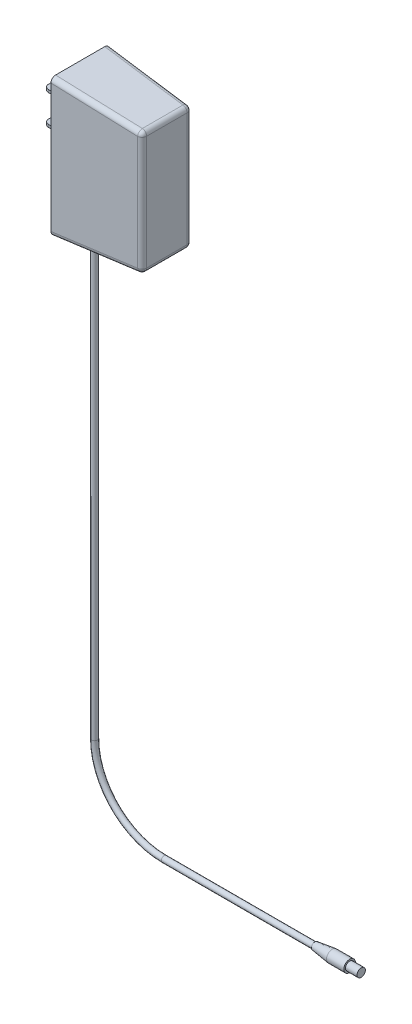
from build123d import *

# Parameters (mm, degrees)
SKETCH2_R           = 1.5875
SKETCH3_R           = 3.175
BOSS_EXTRUDE1_DEPTH = 19.05
SKETCH4_R           = 2.286
BOSS_EXTRUDE2_DEPTH = 6.35
CHAMFER1_SIZE       = 1.27
CHAMFER1_SIZE2      = 9.525
SKETCH5_W           = 47.5
SKETCH5_H           = 75.5
BOSS_EXTRUDE3_DEPTH = 16
SKETCH6_W           = 8
SKETCH6_H           = 1.5
BOSS_EXTRUDE4_DEPTH = 15.88
DRAFT1_ANGLE        = -5
DRAFT2_ANGLE        = -3
FILLET1_R           = 2.54
FILLET2_R           = 2.54


with BuildPart() as part:
    # Sweep1: sweep along a path in Sketch1
    with BuildLine(Plane.XY) as sweep1_path:
        Line((0, 0), (-101.6, 0))
        ThreePointArc((-101.6, 0), (-128.540768363, 11.159231637), (-139.7, 38.1))
        Line((-139.7, 38.1), (-139.7, 355.6))
    # Sketch2 → Sweep1 (sweep)
    with BuildSketch(Plane(origin=(0, 0, 0), x_dir=(0, 0, -1), z_dir=(1, 0, 0))):
        Circle(SKETCH2_R)
    sweep(path=sweep1_path.line)

    # Sketch3 → Boss-Extrude1 (add)
    with BuildSketch(Plane(origin=(0, 0, 0), x_dir=(0, 0, -1), z_dir=(1, 0, 0))):
        Circle(SKETCH3_R)
    extrude(amount=-BOSS_EXTRUDE1_DEPTH)

    # Sketch4 → Boss-Extrude2 (add)
    with BuildSketch(Plane(origin=(0, 0, 0), x_dir=(0, 0, -1), z_dir=(1, 0, 0))):
        Circle(SKETCH4_R)
    extrude(amount=BOSS_EXTRUDE2_DEPTH)

    # Chamfer1
    chamfer1_edges = [part.edges().sort_by_distance(p)[0] for p in [
        (-19.05, 0, 3.175),
    ]]
    chamfer1_side = [part.faces().sort_by_distance(p)[0] for p in [
        (-19.05, 0, 3.085197439),
    ]]
    chamfer(chamfer1_edges, length=CHAMFER1_SIZE, length2=CHAMFER1_SIZE2, reference=chamfer1_side[0])

    # Sketch5 → Boss-Extrude3 (add, symmetric)
    with BuildSketch(Plane.XY):
        with Locations((-123.8875, 317.85)):
            Rectangle(SKETCH5_W, SKETCH5_H)
    extrude(amount=BOSS_EXTRUDE3_DEPTH, both=True)

    # Sketch6 → Boss-Extrude4 (add)
    with BuildSketch(Plane(origin=(-147.6375, 0, 0), x_dir=(0, 0, -1), z_dir=(1, 0, 0))):
        with Locations((0, 336.55)):
            Rectangle(SKETCH6_W, SKETCH6_H)
        with Locations((0, 320.04)):
            Rectangle(SKETCH6_W, SKETCH6_H)
    extrude(amount=-BOSS_EXTRUDE4_DEPTH)

    # Draft1
    draft1_faces = [part.faces().sort_by_distance(p)[0] for p in [
        (-123.804705338, 280.1, 0),
        (-123.8875, 355.6, 0),
    ]]
    draft(draft1_faces, Plane(origin=(-147.6375, 355.6, 16), x_dir=(0, 0, -1), z_dir=(-1, 0, 0)), DRAFT1_ANGLE)

    # Draft2
    draft2_faces = [part.faces().sort_by_distance(p)[0] for p in [
        (-124.348635482, 317.85, -16),
        (-124.348635482, 317.85, 16),
    ]]
    draft(draft2_faces, Plane(origin=(-147.6375, 355.6, 16), x_dir=(0, 0, -1), z_dir=(-1, 0, 0)), DRAFT2_ANGLE)

    # Fillet1
    fillet1_edges = [part.edges().sort_by_distance(p)[0] for p in [
        (-123.8875, 353.522144241, -14.755315242),
        (-100.1375, 351.444288483, 0),
        (-123.8875, 282.177855759, -14.755315242),
        (-100.1375, 317.85, -13.510630484),
        (-100.1375, 284.255711517, 0),
        (-100.1375, 317.85, 13.510630484),
        (-123.8875, 353.522144241, 14.755315242),
        (-123.8875, 282.177855759, 14.755315242),
    ]]
    fillet(fillet1_edges, radius=FILLET1_R)

    # Fillet2
    fillet2_edges = [part.edges().sort_by_distance(p)[0] for p in [
        (-163.5175, 336.55, -4),
        (-163.5175, 336.55, 4),
        (-163.5175, 320.04, -4),
        (-163.5175, 320.04, 4),
    ]]
    fillet(fillet2_edges, radius=FILLET2_R)


solid = part.part
